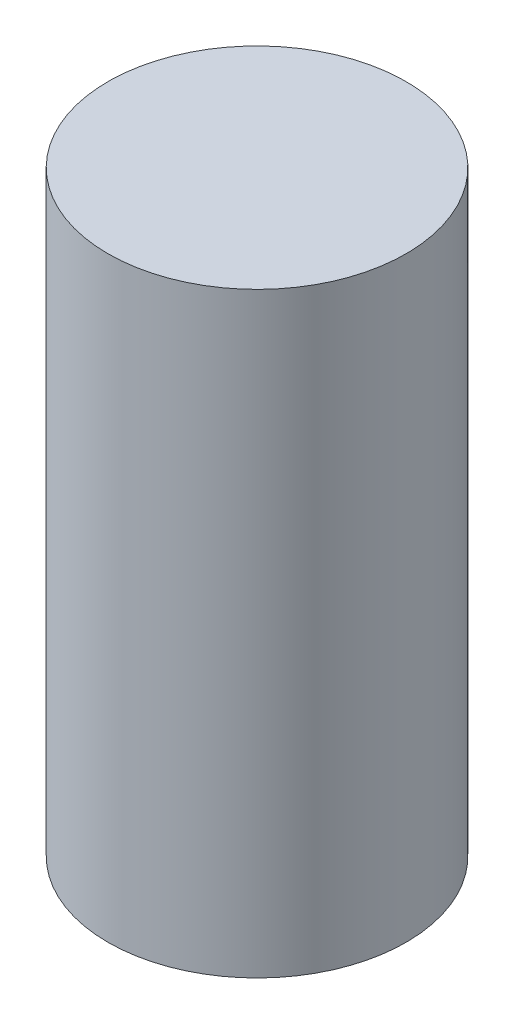
from build123d import *

# Parameters (mm, degrees)
SKETCH1_R           = 5
BOSS_EXTRUDE1_DEPTH = 20


with BuildPart() as part:
    # Sketch1 → Boss-Extrude1 (new body)
    with BuildSketch(Plane(origin=(0, 0, 0), x_dir=(1, 0, 0), z_dir=(0, 1, 0))):
        with Locations((109.817320388, -139.290480902)):
            Circle(SKETCH1_R)
    extrude(amount=BOSS_EXTRUDE1_DEPTH)


solid = part.part
